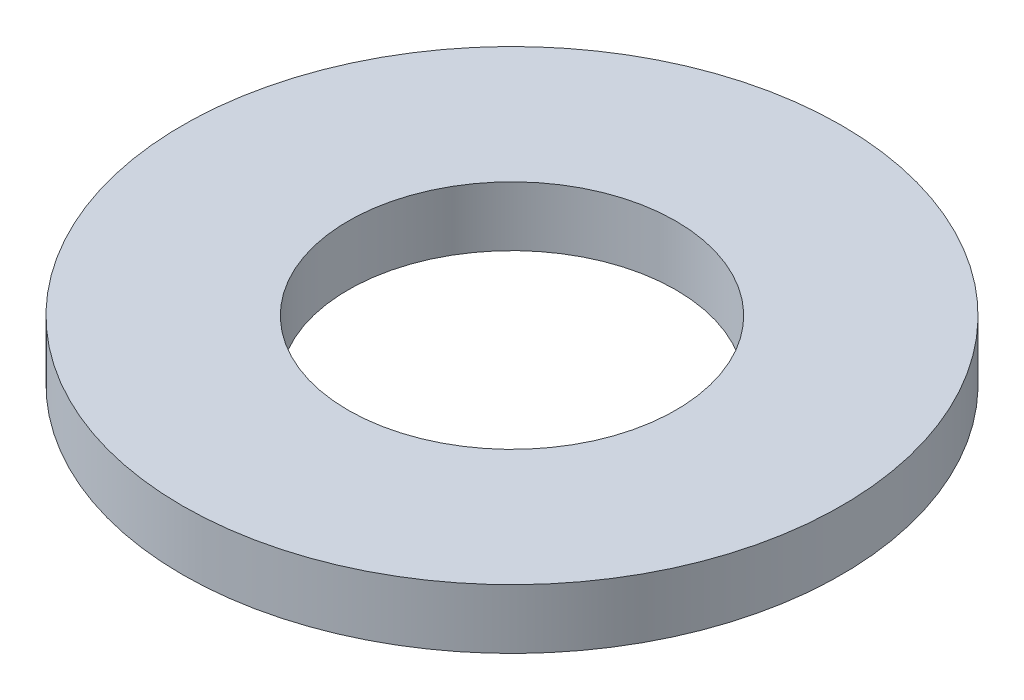
from build123d import *

# Parameters (mm, degrees)
SKETCH1_R           = 4.425
SKETCH1_R_2         = 2.2
BOSS_EXTRUDE1_DEPTH = 0.8


with BuildPart() as part:
    # Sketch1 → Boss-Extrude1 (new body)
    with BuildSketch(Plane(origin=(0, 0, 0), x_dir=(1, 0, 0), z_dir=(0, 1, 0))):
        Circle(SKETCH1_R)
        Circle(SKETCH1_R_2, mode=Mode.SUBTRACT)
    extrude(amount=BOSS_EXTRUDE1_DEPTH)


solid = part.part
